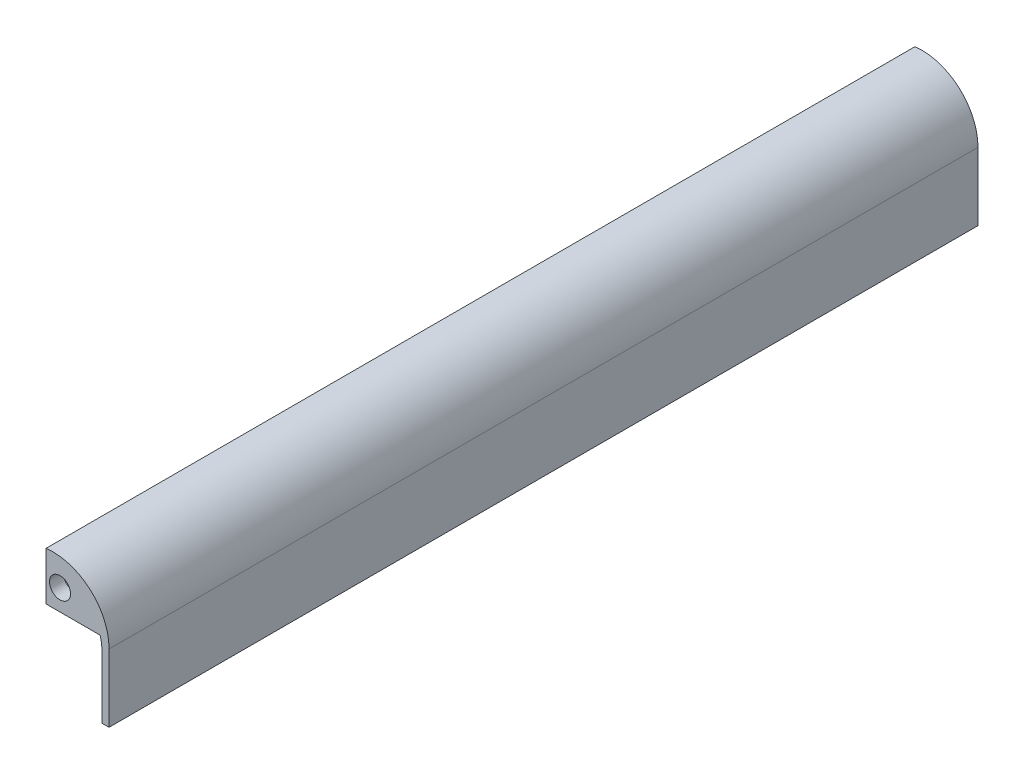
from build123d import *

# Parameters (mm, degrees)
BOSS_EXTRUDE1_DEPTH = 1574.8
BOSS_EXTRUDE2_DEPTH = 25.4
SKETCH3_R           = 19.05
CUT_EXTRUDE1_DEPTH  = 1575.8


with BuildPart() as part:
    # Sketch1 → Boss-Extrude1 (new body)
    with BuildSketch(Plane.XY):
        with BuildLine():
            ThreePointArc((114.3, -101.6), (84.542048969, -29.757951031), (12.7, 0))
            ThreePointArc((12.7, 0), (6.337512086, -0.199414462), (0, -0.796875048))
            Line((0, -0.796875048), (0, -12.7))
            ThreePointArc((0, -12.7), (71.842048969, -42.457951031), (101.6, -114.3))
            Line((101.6, -114.3), (101.6, -224.550826558))
            Line((101.6, -224.550826558), (114.3, -224.550826558))
            Line((114.3, -224.550826558), (114.3, -101.6))
        make_face()
    extrude(amount=BOSS_EXTRUDE1_DEPTH)

    # Sketch2 → Boss-Extrude2 (add)
    with BuildSketch(Plane(origin=(0, 0, 0), x_dir=(-1, 0, 0), z_dir=(0, 0, -1))):
        with BuildLine():
            Line((0, -0.796875048), (0, -88.032487207))
            Line((0, -88.032487207), (-113.39003226, -88.032487207))
            ThreePointArc((-113.39003226, -88.032487207), (-74.652194888, -21.073696542), (0, -0.796875048))
        make_face()
    boss_extrude2 = extrude(amount=-BOSS_EXTRUDE2_DEPTH)

    # Mirror2: Boss-Extrude2 across plane
    add(boss_extrude2.mirror(Plane(origin=(0, 0, 787.4), x_dir=(1, 0, 0), z_dir=(0, 0, -1))))

    # Sketch3 → Cut-Extrude1 (cut, through all)
    with BuildSketch(Plane(origin=(0, 0, 0), x_dir=(-1, 0, 0), z_dir=(0, 0, -1))):
        with Locations((-25.4, -49.932487207)):
            Circle(SKETCH3_R)
    extrude(amount=-CUT_EXTRUDE1_DEPTH, mode=Mode.SUBTRACT)


solid = part.part
